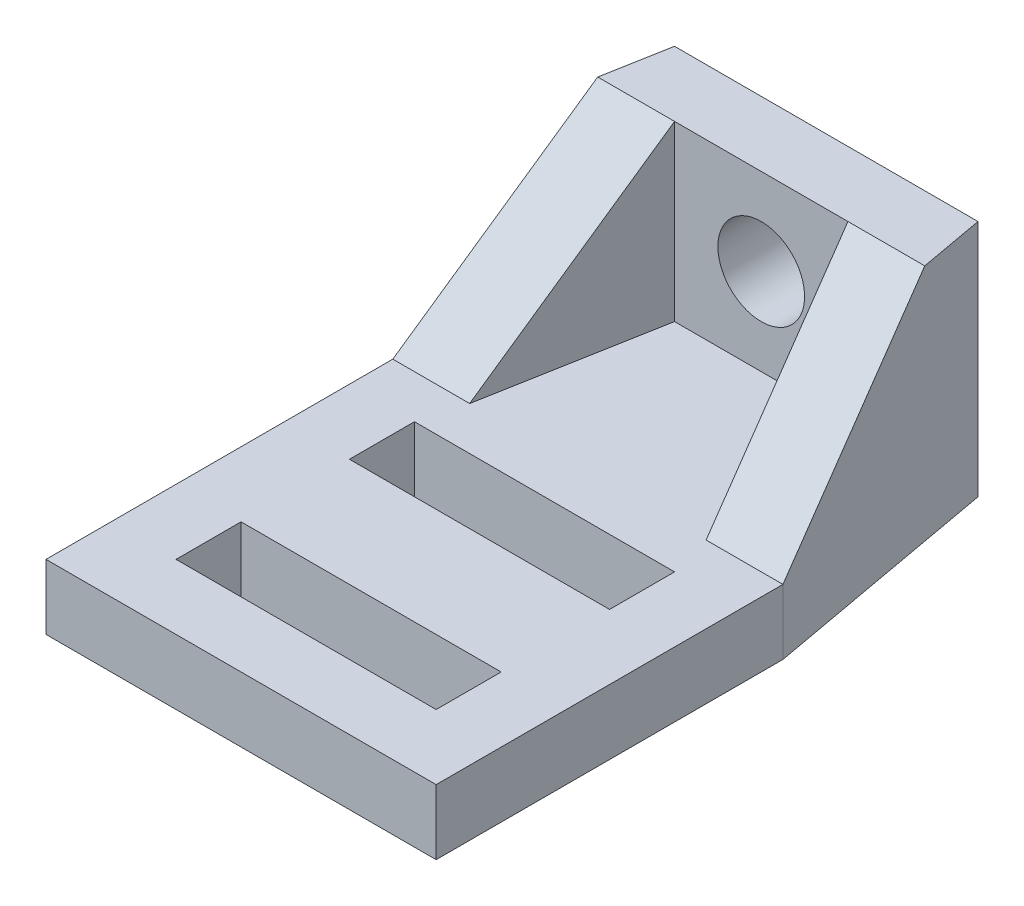
from build123d import *

# Parameters (mm, degrees)
AUFSATZ_LINEAR_AUSTRAGEN1_DEPTH = 3
AUFSATZ_LINEAR_AUSTRAGEN2_DEPTH = 8
SCHNITT_LINEAR_AUSTRAGEN1_DEPTH = 19
F_4_0_4_DURCHMESSER_BOHRUNG1_D  = 4
SKIZZE7_W                       = 12
SKIZZE7_H                       = 3
SCHNITT_LINEAR_AUSTRAGEN2_DEPTH = 4


with BuildPart() as part:
    # Skizze1 → Aufsatz-Linear austragen1 (new body)
    with BuildSketch(Plane(origin=(0, 0, 0), x_dir=(1, 0, 0), z_dir=(0, 1, 0))):
        Polygon((9, -13.5), (-9, -13.5), (-9, 2.5), (-7, 13.5), (7, 13.5), (9, 2.5), align=None)
    extrude(amount=AUFSATZ_LINEAR_AUSTRAGEN1_DEPTH)

    # Skizze2 → Aufsatz-Linear austragen2 (add)
    with BuildSketch(Plane(origin=(0, 3, 0), x_dir=(1, 0, 0), z_dir=(0, 1, 0))):
        Polygon((-9, 2.5), (-7, 13.5), (7, 13.5), (9, 2.5), (5.454545455, 2.5), (4, 10.5), (-4, 10.5), (-5.454545455, 2.5), align=None)
    extrude(amount=AUFSATZ_LINEAR_AUSTRAGEN2_DEPTH)

    # Skizze3 → Schnitt-Linear austragen1 (cut, through all)
    with BuildSketch(Plane.ZY.offset(9)):
        Polygon((-2.5, 3), (-10.5, 11), (-10.5, 11.548475308), (-1.609095569, 11.548475308), (-1.609095569, 3.67540056), align=None)
    extrude(amount=-SCHNITT_LINEAR_AUSTRAGEN1_DEPTH, mode=Mode.SUBTRACT)

    # Ø4.0 (4) Durchmesser Bohrung1 (through all)
    with Locations(Plane(origin=(0, 0, -13.5), x_dir=(-1, 0, 0), z_dir=(0, 0, -1))):
        with Locations((0, 7)):
            Hole(F_4_0_4_DURCHMESSER_BOHRUNG1_D / 2)

    # Skizze7 → Schnitt-Linear austragen2 (cut, through all)
    with BuildSketch(Plane(origin=(0, 3, 0), x_dir=(1, 0, 0), z_dir=(0, 1, 0))):
        with Locations((0, -9)):
            Rectangle(SKIZZE7_W, SKIZZE7_H)
        with Locations((0, -1)):
            Rectangle(SKIZZE7_W, SKIZZE7_H)
    extrude(amount=-SCHNITT_LINEAR_AUSTRAGEN2_DEPTH, mode=Mode.SUBTRACT)


solid = part.part
